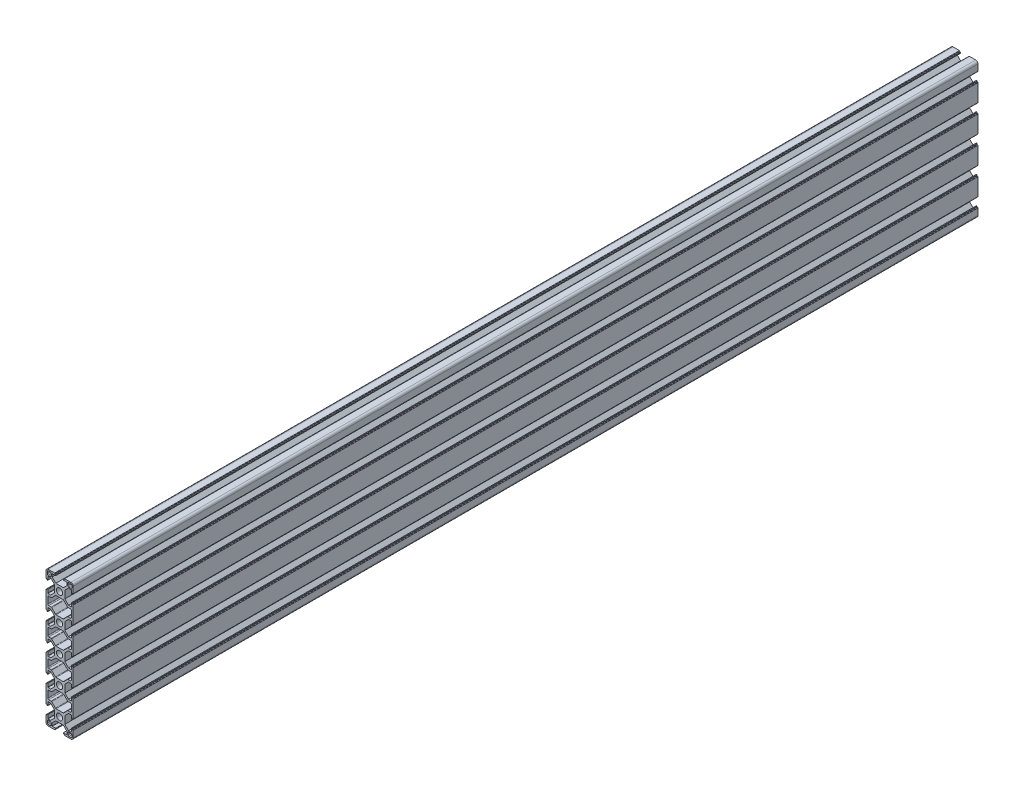
from build123d import *

# Parameters (mm, degrees)
SKETCH_1_R      = 3.4
EXTRUDE_1_DEPTH = 1000


with BuildPart() as part:
    # Эскиз1 → Бобышка-Вытянуть1 (new body)
    with BuildSketch(Plane.XY):
        with BuildLine():
            Line((-15, 8.25), (-15, 12.5))
            ThreePointArc((-15, 12.5), (-14.267766953, 14.267766953), (-12.5, 15))
            Line((-12.5, 15), (-8.25, 15))
            Line((-8.25, 15), (-5.5, 15))
            ThreePointArc((-5.5, 15), (-5.287867966, 14.912132034), (-5.2, 14.7))
            Line((-5.2, 14.7), (-5.2, 14.3))
            ThreePointArc((-5.2, 14.3), (-5.112132034, 14.087867966), (-4.9, 14))
            Line((-4.9, 14), (-4.4, 14))
            ThreePointArc((-4.4, 14), (-4.187867966, 13.912132034), (-4.1, 13.7))
            Line((-4.1, 13.7), (-4.1, 13.3))
            ThreePointArc((-4.1, 13.3), (-4.187867966, 13.087867966), (-4.4, 13))
            Line((-4.4, 13), (-7.95, 13))
            ThreePointArc((-7.95, 13), (-8.162132034, 12.912132034), (-8.25, 12.7))
            Line((-8.25, 12.7), (-8.25, 9.85))
            Line((-8.25, 9.85), (-4.2, 5.8))
            Line((-4.2, 5.8), (4.2, 5.8))
            Line((4.2, 5.8), (8.25, 9.85))
            Line((8.25, 9.85), (8.25, 12.7))
            ThreePointArc((8.25, 12.7), (8.162132034, 12.912132034), (7.95, 13))
            Line((7.95, 13), (4.4, 13))
            ThreePointArc((4.4, 13), (4.187867966, 13.087867966), (4.1, 13.3))
            Line((4.1, 13.3), (4.1, 13.7))
            ThreePointArc((4.1, 13.7), (4.187867966, 13.912132034), (4.4, 14))
            Line((4.4, 14), (4.9, 14))
            ThreePointArc((4.9, 14), (5.112132034, 14.087867966), (5.2, 14.3))
            Line((5.2, 14.3), (5.2, 14.7))
            ThreePointArc((5.2, 14.7), (5.287867966, 14.912132034), (5.5, 15))
            Line((5.5, 15), (8.25, 15))
            Line((8.25, 15), (12.5, 15))
            ThreePointArc((12.5, 15), (14.267766953, 14.267766953), (15, 12.5))
            Line((15, 12.5), (15, 8.25))
            Line((15, 8.25), (15, 5.5))
            ThreePointArc((15, 5.5), (14.912132034, 5.287867966), (14.7, 5.2))
            Line((14.7, 5.2), (14.3, 5.2))
            ThreePointArc((14.3, 5.2), (14.087867966, 5.112132034), (14, 4.9))
            Line((14, 4.9), (14, 4.4))
            ThreePointArc((14, 4.4), (13.912132034, 4.187867966), (13.7, 4.1))
            Line((13.7, 4.1), (13.3, 4.1))
            ThreePointArc((13.3, 4.1), (13.087867966, 4.187867966), (13, 4.4))
            Line((13, 4.4), (13, 7.95))
            ThreePointArc((13, 7.95), (12.912132034, 8.162132034), (12.7, 8.25))
            Line((12.7, 8.25), (9.85, 8.25))
            Line((9.85, 8.25), (5.8, 4.2))
            Line((5.8, 4.2), (5.8, -4.2))
            Line((5.8, -4.2), (9.85, -8.25))
            Line((9.85, -8.25), (12.7, -8.25))
            ThreePointArc((12.7, -8.25), (12.912132034, -8.162132034), (13, -7.95))
            Line((13, -7.95), (13, -4.4))
            ThreePointArc((13, -4.4), (13.087867966, -4.187867966), (13.3, -4.1))
            Line((13.3, -4.1), (13.7, -4.1))
            ThreePointArc((13.7, -4.1), (13.912132034, -4.187867966), (14, -4.4))
            Line((14, -4.4), (14, -4.9))
            ThreePointArc((14, -4.9), (14.087867966, -5.112132034), (14.3, -5.2))
            Line((14.3, -5.2), (14.7, -5.2))
            ThreePointArc((14.7, -5.2), (14.912132034, -5.287867966), (15, -5.5))
            Line((15, -5.5), (15, -8.25))
            Line((15, -8.25), (15, -21.75))
            Line((15, -21.75), (15, -24.5))
            ThreePointArc((15, -24.5), (14.912132034, -24.712132034), (14.7, -24.8))
            Line((14.7, -24.8), (14.3, -24.8))
            ThreePointArc((14.3, -24.8), (14.087867966, -24.887867966), (14, -25.1))
            Line((14, -25.1), (14, -25.6))
            ThreePointArc((14, -25.6), (13.912132034, -25.812132034), (13.7, -25.9))
            Line((13.7, -25.9), (13.3, -25.9))
            ThreePointArc((13.3, -25.9), (13.087867966, -25.812132034), (13, -25.6))
            Line((13, -25.6), (13, -22.05))
            ThreePointArc((13, -22.05), (12.912132034, -21.837867966), (12.7, -21.75))
            Line((12.7, -21.75), (9.85, -21.75))
            Line((9.85, -21.75), (5.8, -25.8))
            Line((5.8, -25.8), (5.8, -34.2))
            Line((5.8, -34.2), (9.85, -38.25))
            Line((9.85, -38.25), (12.7, -38.25))
            ThreePointArc((12.7, -38.25), (12.912132034, -38.162132034), (13, -37.95))
            Line((13, -37.95), (13, -34.4))
            ThreePointArc((13, -34.4), (13.087867966, -34.187867966), (13.3, -34.1))
            Line((13.3, -34.1), (13.7, -34.1))
            ThreePointArc((13.7, -34.1), (13.912132034, -34.187867966), (14, -34.4))
            Line((14, -34.4), (14, -34.9))
            ThreePointArc((14, -34.9), (14.087867966, -35.112132034), (14.3, -35.2))
            Line((14.3, -35.2), (14.7, -35.2))
            ThreePointArc((14.7, -35.2), (14.912132034, -35.287867966), (15, -35.5))
            Line((15, -35.5), (15, -38.25))
            Line((15, -38.25), (15, -51.75))
            Line((15, -51.75), (15, -54.5))
            ThreePointArc((15, -54.5), (14.912132034, -54.712132034), (14.7, -54.8))
            Line((14.7, -54.8), (14.3, -54.8))
            ThreePointArc((14.3, -54.8), (14.087867966, -54.887867966), (14, -55.1))
            Line((14, -55.1), (14, -55.6))
            ThreePointArc((14, -55.6), (13.912132034, -55.812132034), (13.7, -55.9))
            Line((13.7, -55.9), (13.3, -55.9))
            ThreePointArc((13.3, -55.9), (13.087867966, -55.812132034), (13, -55.6))
            Line((13, -55.6), (13, -52.05))
            ThreePointArc((13, -52.05), (12.912132034, -51.837867966), (12.7, -51.75))
            Line((12.7, -51.75), (9.85, -51.75))
            Line((9.85, -51.75), (5.8, -55.8))
            Line((5.8, -55.8), (5.8, -64.2))
            Line((5.8, -64.2), (9.85, -68.25))
            Line((9.85, -68.25), (12.7, -68.25))
            ThreePointArc((12.7, -68.25), (12.912132034, -68.162132034), (13, -67.95))
            Line((13, -67.95), (13, -64.4))
            ThreePointArc((13, -64.4), (13.087867966, -64.187867966), (13.3, -64.1))
            Line((13.3, -64.1), (13.7, -64.1))
            ThreePointArc((13.7, -64.1), (13.912132034, -64.187867966), (14, -64.4))
            Line((14, -64.4), (14, -64.9))
            ThreePointArc((14, -64.9), (14.087867966, -65.112132034), (14.3, -65.2))
            Line((14.3, -65.2), (14.7, -65.2))
            ThreePointArc((14.7, -65.2), (14.912132034, -65.287867966), (15, -65.5))
            Line((15, -65.5), (15, -68.25))
            Line((15, -68.25), (15, -81.75))
            Line((15, -81.75), (15, -84.5))
            ThreePointArc((15, -84.5), (14.912132034, -84.712132034), (14.7, -84.8))
            Line((14.7, -84.8), (14.3, -84.8))
            ThreePointArc((14.3, -84.8), (14.087867966, -84.887867966), (14, -85.1))
            Line((14, -85.1), (14, -85.6))
            ThreePointArc((14, -85.6), (13.912132034, -85.812132034), (13.7, -85.9))
            Line((13.7, -85.9), (13.3, -85.9))
            ThreePointArc((13.3, -85.9), (13.087867966, -85.812132034), (13, -85.6))
            Line((13, -85.6), (13, -82.05))
            ThreePointArc((13, -82.05), (12.912132034, -81.837867966), (12.7, -81.75))
            Line((12.7, -81.75), (9.85, -81.75))
            Line((9.85, -81.75), (5.8, -85.8))
            Line((5.8, -85.8), (5.8, -94.2))
            Line((5.8, -94.2), (9.85, -98.25))
            Line((9.85, -98.25), (12.7, -98.25))
            ThreePointArc((12.7, -98.25), (12.912132034, -98.162132034), (13, -97.95))
            Line((13, -97.95), (13, -94.4))
            ThreePointArc((13, -94.4), (13.087867966, -94.187867966), (13.3, -94.1))
            Line((13.3, -94.1), (13.7, -94.1))
            ThreePointArc((13.7, -94.1), (13.912132034, -94.187867966), (14, -94.4))
            Line((14, -94.4), (14, -94.9))
            ThreePointArc((14, -94.9), (14.087867966, -95.112132034), (14.3, -95.2))
            Line((14.3, -95.2), (14.7, -95.2))
            ThreePointArc((14.7, -95.2), (14.912132034, -95.287867966), (15, -95.5))
            Line((15, -95.5), (15, -98.25))
            Line((15, -98.25), (15, -111.75))
            Line((15, -111.75), (15, -114.5))
            ThreePointArc((15, -114.5), (14.912132034, -114.712132034), (14.7, -114.8))
            Line((14.7, -114.8), (14.3, -114.8))
            ThreePointArc((14.3, -114.8), (14.087867966, -114.887867966), (14, -115.1))
            Line((14, -115.1), (14, -115.6))
            ThreePointArc((14, -115.6), (13.912132034, -115.812132034), (13.7, -115.9))
            Line((13.7, -115.9), (13.3, -115.9))
            ThreePointArc((13.3, -115.9), (13.087867966, -115.812132034), (13, -115.6))
            Line((13, -115.6), (13, -112.05))
            ThreePointArc((13, -112.05), (12.912132034, -111.837867966), (12.7, -111.75))
            Line((12.7, -111.75), (9.85, -111.75))
            Line((9.85, -111.75), (5.8, -115.8))
            Line((5.8, -115.8), (5.8, -124.2))
            Line((5.8, -124.2), (9.85, -128.25))
            Line((9.85, -128.25), (12.7, -128.25))
            ThreePointArc((12.7, -128.25), (12.912132034, -128.162132034), (13, -127.95))
            Line((13, -127.95), (13, -124.4))
            ThreePointArc((13, -124.4), (13.087867966, -124.187867966), (13.3, -124.1))
            Line((13.3, -124.1), (13.7, -124.1))
            ThreePointArc((13.7, -124.1), (13.912132034, -124.187867966), (14, -124.4))
            Line((14, -124.4), (14, -124.9))
            ThreePointArc((14, -124.9), (14.087867966, -125.112132034), (14.3, -125.2))
            Line((14.3, -125.2), (14.7, -125.2))
            ThreePointArc((14.7, -125.2), (14.912132034, -125.287867966), (15, -125.5))
            Line((15, -125.5), (15, -128.25))
            Line((15, -128.25), (15, -132.5))
            ThreePointArc((15, -132.5), (14.267766953, -134.267766953), (12.5, -135))
            Line((12.5, -135), (8.25, -135))
            Line((8.25, -135), (5.5, -135))
            ThreePointArc((5.5, -135), (5.287867966, -134.912132034), (5.2, -134.7))
            Line((5.2, -134.7), (5.2, -134.3))
            ThreePointArc((5.2, -134.3), (5.112132034, -134.087867966), (4.9, -134))
            Line((4.9, -134), (4.4, -134))
            ThreePointArc((4.4, -134), (4.187867966, -133.912132034), (4.1, -133.7))
            Line((4.1, -133.7), (4.1, -133.3))
            ThreePointArc((4.1, -133.3), (4.187867966, -133.087867966), (4.4, -133))
            Line((4.4, -133), (7.95, -133))
            ThreePointArc((7.95, -133), (8.162132034, -132.912132034), (8.25, -132.7))
            Line((8.25, -132.7), (8.25, -129.85))
            Line((8.25, -129.85), (4.2, -125.8))
            Line((4.2, -125.8), (-4.2, -125.8))
            Line((-4.2, -125.8), (-8.25, -129.85))
            Line((-8.25, -129.85), (-8.25, -132.7))
            ThreePointArc((-8.25, -132.7), (-8.162132034, -132.912132034), (-7.95, -133))
            Line((-7.95, -133), (-4.4, -133))
            ThreePointArc((-4.4, -133), (-4.187867966, -133.087867966), (-4.1, -133.3))
            Line((-4.1, -133.3), (-4.1, -133.7))
            ThreePointArc((-4.1, -133.7), (-4.187867966, -133.912132034), (-4.4, -134))
            Line((-4.4, -134), (-4.9, -134))
            ThreePointArc((-4.9, -134), (-5.112132034, -134.087867966), (-5.2, -134.3))
            Line((-5.2, -134.3), (-5.2, -134.7))
            ThreePointArc((-5.2, -134.7), (-5.287867966, -134.912132034), (-5.5, -135))
            Line((-5.5, -135), (-8.25, -135))
            Line((-8.25, -135), (-12.5, -135))
            ThreePointArc((-12.5, -135), (-14.267766953, -134.267766953), (-15, -132.5))
            Line((-15, -132.5), (-15, -128.25))
            Line((-15, -128.25), (-15, -125.5))
            ThreePointArc((-15, -125.5), (-14.912132034, -125.287867966), (-14.7, -125.2))
            Line((-14.7, -125.2), (-14.3, -125.2))
            ThreePointArc((-14.3, -125.2), (-14.087867966, -125.112132034), (-14, -124.9))
            Line((-14, -124.9), (-14, -124.4))
            ThreePointArc((-14, -124.4), (-13.912132034, -124.187867966), (-13.7, -124.1))
            Line((-13.7, -124.1), (-13.3, -124.1))
            ThreePointArc((-13.3, -124.1), (-13.087867966, -124.187867966), (-13, -124.4))
            Line((-13, -124.4), (-13, -127.95))
            ThreePointArc((-13, -127.95), (-12.912132034, -128.162132034), (-12.7, -128.25))
            Line((-12.7, -128.25), (-9.85, -128.25))
            Line((-9.85, -128.25), (-5.8, -124.2))
            Line((-5.8, -124.2), (-5.8, -115.8))
            Line((-5.8, -115.8), (-9.85, -111.75))
            Line((-9.85, -111.75), (-12.7, -111.75))
            ThreePointArc((-12.7, -111.75), (-12.912132034, -111.837867966), (-13, -112.05))
            Line((-13, -112.05), (-13, -115.6))
            ThreePointArc((-13, -115.6), (-13.087867966, -115.812132034), (-13.3, -115.9))
            Line((-13.3, -115.9), (-13.7, -115.9))
            ThreePointArc((-13.7, -115.9), (-13.912132034, -115.812132034), (-14, -115.6))
            Line((-14, -115.6), (-14, -115.1))
            ThreePointArc((-14, -115.1), (-14.087867966, -114.887867966), (-14.3, -114.8))
            Line((-14.3, -114.8), (-14.7, -114.8))
            ThreePointArc((-14.7, -114.8), (-14.912132034, -114.712132034), (-15, -114.5))
            Line((-15, -114.5), (-15, -111.75))
            Line((-15, -111.75), (-15, -98.25))
            Line((-15, -98.25), (-15, -95.5))
            ThreePointArc((-15, -95.5), (-14.912132034, -95.287867966), (-14.7, -95.2))
            Line((-14.7, -95.2), (-14.3, -95.2))
            ThreePointArc((-14.3, -95.2), (-14.087867966, -95.112132034), (-14, -94.9))
            Line((-14, -94.9), (-14, -94.4))
            ThreePointArc((-14, -94.4), (-13.912132034, -94.187867966), (-13.7, -94.1))
            Line((-13.7, -94.1), (-13.3, -94.1))
            ThreePointArc((-13.3, -94.1), (-13.087867966, -94.187867966), (-13, -94.4))
            Line((-13, -94.4), (-13, -97.95))
            ThreePointArc((-13, -97.95), (-12.912132034, -98.162132034), (-12.7, -98.25))
            Line((-12.7, -98.25), (-9.85, -98.25))
            Line((-9.85, -98.25), (-5.8, -94.2))
            Line((-5.8, -94.2), (-5.8, -85.8))
            Line((-5.8, -85.8), (-9.85, -81.75))
            Line((-9.85, -81.75), (-12.7, -81.75))
            ThreePointArc((-12.7, -81.75), (-12.912132034, -81.837867966), (-13, -82.05))
            Line((-13, -82.05), (-13, -85.6))
            ThreePointArc((-13, -85.6), (-13.087867966, -85.812132034), (-13.3, -85.9))
            Line((-13.3, -85.9), (-13.7, -85.9))
            ThreePointArc((-13.7, -85.9), (-13.912132034, -85.812132034), (-14, -85.6))
            Line((-14, -85.6), (-14, -85.1))
            ThreePointArc((-14, -85.1), (-14.087867966, -84.887867966), (-14.3, -84.8))
            Line((-14.3, -84.8), (-14.7, -84.8))
            ThreePointArc((-14.7, -84.8), (-14.912132034, -84.712132034), (-15, -84.5))
            Line((-15, -84.5), (-15, -81.75))
            Line((-15, -81.75), (-15, -68.25))
            Line((-15, -68.25), (-15, -65.5))
            ThreePointArc((-15, -65.5), (-14.912132034, -65.287867966), (-14.7, -65.2))
            Line((-14.7, -65.2), (-14.3, -65.2))
            ThreePointArc((-14.3, -65.2), (-14.087867966, -65.112132034), (-14, -64.9))
            Line((-14, -64.9), (-14, -64.4))
            ThreePointArc((-14, -64.4), (-13.912132034, -64.187867966), (-13.7, -64.1))
            Line((-13.7, -64.1), (-13.3, -64.1))
            ThreePointArc((-13.3, -64.1), (-13.087867966, -64.187867966), (-13, -64.4))
            Line((-13, -64.4), (-13, -67.95))
            ThreePointArc((-13, -67.95), (-12.912132034, -68.162132034), (-12.7, -68.25))
            Line((-12.7, -68.25), (-9.85, -68.25))
            Line((-9.85, -68.25), (-5.8, -64.2))
            Line((-5.8, -64.2), (-5.8, -55.8))
            Line((-5.8, -55.8), (-9.85, -51.75))
            Line((-9.85, -51.75), (-12.7, -51.75))
            ThreePointArc((-12.7, -51.75), (-12.912132034, -51.837867966), (-13, -52.05))
            Line((-13, -52.05), (-13, -55.6))
            ThreePointArc((-13, -55.6), (-13.087867966, -55.812132034), (-13.3, -55.9))
            Line((-13.3, -55.9), (-13.7, -55.9))
            ThreePointArc((-13.7, -55.9), (-13.912132034, -55.812132034), (-14, -55.6))
            Line((-14, -55.6), (-14, -55.1))
            ThreePointArc((-14, -55.1), (-14.087867966, -54.887867966), (-14.3, -54.8))
            Line((-14.3, -54.8), (-14.7, -54.8))
            ThreePointArc((-14.7, -54.8), (-14.912132034, -54.712132034), (-15, -54.5))
            Line((-15, -54.5), (-15, -51.75))
            Line((-15, -51.75), (-15, -38.25))
            Line((-15, -38.25), (-15, -35.5))
            ThreePointArc((-15, -35.5), (-14.912132034, -35.287867966), (-14.7, -35.2))
            Line((-14.7, -35.2), (-14.3, -35.2))
            ThreePointArc((-14.3, -35.2), (-14.087867966, -35.112132034), (-14, -34.9))
            Line((-14, -34.9), (-14, -34.4))
            ThreePointArc((-14, -34.4), (-13.912132034, -34.187867966), (-13.7, -34.1))
            Line((-13.7, -34.1), (-13.3, -34.1))
            ThreePointArc((-13.3, -34.1), (-13.087867966, -34.187867966), (-13, -34.4))
            Line((-13, -34.4), (-13, -37.95))
            ThreePointArc((-13, -37.95), (-12.912132034, -38.162132034), (-12.7, -38.25))
            Line((-12.7, -38.25), (-9.85, -38.25))
            Line((-9.85, -38.25), (-5.8, -34.2))
            Line((-5.8, -34.2), (-5.8, -25.8))
            Line((-5.8, -25.8), (-9.85, -21.75))
            Line((-9.85, -21.75), (-12.7, -21.75))
            ThreePointArc((-12.7, -21.75), (-12.912132034, -21.837867966), (-13, -22.05))
            Line((-13, -22.05), (-13, -25.6))
            ThreePointArc((-13, -25.6), (-13.087867966, -25.812132034), (-13.3, -25.9))
            Line((-13.3, -25.9), (-13.7, -25.9))
            ThreePointArc((-13.7, -25.9), (-13.912132034, -25.812132034), (-14, -25.6))
            Line((-14, -25.6), (-14, -25.1))
            ThreePointArc((-14, -25.1), (-14.087867966, -24.887867966), (-14.3, -24.8))
            Line((-14.3, -24.8), (-14.7, -24.8))
            ThreePointArc((-14.7, -24.8), (-14.912132034, -24.712132034), (-15, -24.5))
            Line((-15, -24.5), (-15, -21.75))
            Line((-15, -21.75), (-15, -8.25))
            Line((-15, -8.25), (-15, -5.5))
            ThreePointArc((-15, -5.5), (-14.912132034, -5.287867966), (-14.7, -5.2))
            Line((-14.7, -5.2), (-14.3, -5.2))
            ThreePointArc((-14.3, -5.2), (-14.087867966, -5.112132034), (-14, -4.9))
            Line((-14, -4.9), (-14, -4.4))
            ThreePointArc((-14, -4.4), (-13.912132034, -4.187867966), (-13.7, -4.1))
            Line((-13.7, -4.1), (-13.3, -4.1))
            ThreePointArc((-13.3, -4.1), (-13.087867966, -4.187867966), (-13, -4.4))
            Line((-13, -4.4), (-13, -7.95))
            ThreePointArc((-13, -7.95), (-12.912132034, -8.162132034), (-12.7, -8.25))
            Line((-12.7, -8.25), (-9.85, -8.25))
            Line((-9.85, -8.25), (-5.8, -4.2))
            Line((-5.8, -4.2), (-5.8, 4.2))
            Line((-5.8, 4.2), (-9.85, 8.25))
            Line((-9.85, 8.25), (-12.7, 8.25))
            ThreePointArc((-12.7, 8.25), (-12.912132034, 8.162132034), (-13, 7.95))
            Line((-13, 7.95), (-13, 4.4))
            ThreePointArc((-13, 4.4), (-13.087867966, 4.187867966), (-13.3, 4.1))
            Line((-13.3, 4.1), (-13.7, 4.1))
            ThreePointArc((-13.7, 4.1), (-13.912132034, 4.187867966), (-14, 4.4))
            Line((-14, 4.4), (-14, 4.9))
            ThreePointArc((-14, 4.9), (-14.087867966, 5.112132034), (-14.3, 5.2))
            Line((-14.3, 5.2), (-14.7, 5.2))
            ThreePointArc((-14.7, 5.2), (-14.912132034, 5.287867966), (-15, 5.5))
            Line((-15, 5.5), (-15, 8.25))
        make_face()
        Circle(SKETCH_1_R, mode=Mode.SUBTRACT)
        with Locations((0, -30)):
            Circle(SKETCH_1_R, mode=Mode.SUBTRACT)
        with Locations((0, -60)):
            Circle(SKETCH_1_R, mode=Mode.SUBTRACT)
        with Locations((0, -90)):
            Circle(SKETCH_1_R, mode=Mode.SUBTRACT)
        with Locations((0, -120)):
            Circle(SKETCH_1_R, mode=Mode.SUBTRACT)
        with BuildLine():
            Line((12.55, 9.35), (10.35, 9.35))
            ThreePointArc((10.35, 9.35), (9.642893219, 9.642893219), (9.35, 10.35))
            Line((9.35, 10.35), (9.35, 12.55))
            ThreePointArc((9.35, 12.55), (9.642893219, 13.257106781), (10.35, 13.55))
            Line((10.35, 13.55), (12.55, 13.55))
            ThreePointArc((12.55, 13.55), (13.257106781, 13.257106781), (13.55, 12.55))
            Line((13.55, 12.55), (13.55, 10.35))
            ThreePointArc((13.55, 10.35), (13.257106781, 9.642893219), (12.55, 9.35))
        make_face(mode=Mode.SUBTRACT)
        with BuildLine():
            Line((-12.55, 13.55), (-10.35, 13.55))
            ThreePointArc((-10.35, 13.55), (-9.642893219, 13.257106781), (-9.35, 12.55))
            Line((-9.35, 12.55), (-9.35, 10.35))
            ThreePointArc((-9.35, 10.35), (-9.642893219, 9.642893219), (-10.35, 9.35))
            Line((-10.35, 9.35), (-12.55, 9.35))
            ThreePointArc((-12.55, 9.35), (-13.257106781, 9.642893219), (-13.55, 10.35))
            Line((-13.55, 10.35), (-13.55, 12.55))
            ThreePointArc((-13.55, 12.55), (-13.257106781, 13.257106781), (-12.55, 13.55))
        make_face(mode=Mode.SUBTRACT)
        with BuildLine():
            Line((8.695836944, -40.207106781), (4.581623382, -36.092893219))
            ThreePointArc((4.581623382, -36.092893219), (4.257200033, -35.876120467), (3.8745166, -35.8))
            Line((3.8745166, -35.8), (-3.8745166, -35.8))
            ThreePointArc((-3.8745166, -35.8), (-4.257200033, -35.876120467), (-4.581623382, -36.092893219))
            Line((-4.581623382, -36.092893219), (-8.695836944, -40.207106781))
            ThreePointArc((-8.695836944, -40.207106781), (-9.020260293, -40.423879533), (-9.402943725, -40.5))
            Line((-9.402943725, -40.5), (-12, -40.5))
            ThreePointArc((-12, -40.5), (-12.707106781, -40.792893219), (-13, -41.5))
            Line((-13, -41.5), (-13, -48.5))
            ThreePointArc((-13, -48.5), (-12.707106781, -49.207106781), (-12, -49.5))
            Line((-12, -49.5), (-9.402943725, -49.5))
            ThreePointArc((-9.402943725, -49.5), (-9.020260293, -49.576120467), (-8.695836944, -49.792893219))
            Line((-8.695836944, -49.792893219), (-4.581623382, -53.907106781))
            ThreePointArc((-4.581623382, -53.907106781), (-4.257200033, -54.123879533), (-3.8745166, -54.2))
            Line((-3.8745166, -54.2), (3.8745166, -54.2))
            ThreePointArc((3.8745166, -54.2), (4.257200033, -54.123879533), (4.581623382, -53.907106781))
            Line((4.581623382, -53.907106781), (8.695836944, -49.792893219))
            ThreePointArc((8.695836944, -49.792893219), (9.020260293, -49.576120467), (9.402943725, -49.5))
            Line((9.402943725, -49.5), (12, -49.5))
            ThreePointArc((12, -49.5), (12.707106781, -49.207106781), (13, -48.5))
            Line((13, -48.5), (13, -41.5))
            ThreePointArc((13, -41.5), (12.707106781, -40.792893219), (12, -40.5))
            Line((12, -40.5), (9.402943725, -40.5))
            ThreePointArc((9.402943725, -40.5), (9.020260293, -40.423879533), (8.695836944, -40.207106781))
        make_face(mode=Mode.SUBTRACT)
        with BuildLine():
            Line((-13, -18.5), (-13, -11.5))
            ThreePointArc((-13, -11.5), (-12.707106781, -10.792893219), (-12, -10.5))
            Line((-12, -10.5), (-9.402943725, -10.5))
            ThreePointArc((-9.402943725, -10.5), (-9.020260293, -10.423879533), (-8.695836944, -10.207106781))
            Line((-8.695836944, -10.207106781), (-4.581623382, -6.092893219))
            ThreePointArc((-4.581623382, -6.092893219), (-4.257200033, -5.876120467), (-3.8745166, -5.8))
            Line((-3.8745166, -5.8), (3.8745166, -5.8))
            ThreePointArc((3.8745166, -5.8), (4.257200033, -5.876120467), (4.581623382, -6.092893219))
            Line((4.581623382, -6.092893219), (8.695836944, -10.207106781))
            ThreePointArc((8.695836944, -10.207106781), (9.020260293, -10.423879533), (9.402943725, -10.5))
            Line((9.402943725, -10.5), (12, -10.5))
            ThreePointArc((12, -10.5), (12.707106781, -10.792893219), (13, -11.5))
            Line((13, -11.5), (13, -18.5))
            ThreePointArc((13, -18.5), (12.707106781, -19.207106781), (12, -19.5))
            Line((12, -19.5), (9.402943725, -19.5))
            ThreePointArc((9.402943725, -19.5), (9.020260293, -19.576120467), (8.695836944, -19.792893219))
            Line((8.695836944, -19.792893219), (4.581623382, -23.907106781))
            ThreePointArc((4.581623382, -23.907106781), (4.257200033, -24.123879533), (3.8745166, -24.2))
            Line((3.8745166, -24.2), (-3.8745166, -24.2))
            ThreePointArc((-3.8745166, -24.2), (-4.257200033, -24.123879533), (-4.581623382, -23.907106781))
            Line((-4.581623382, -23.907106781), (-8.695836944, -19.792893219))
            ThreePointArc((-8.695836944, -19.792893219), (-9.020260293, -19.576120467), (-9.402943725, -19.5))
            Line((-9.402943725, -19.5), (-12, -19.5))
            ThreePointArc((-12, -19.5), (-12.707106781, -19.207106781), (-13, -18.5))
        make_face(mode=Mode.SUBTRACT)
        with BuildLine():
            Line((8.695836944, -70.207106781), (4.581623382, -66.092893219))
            ThreePointArc((4.581623382, -66.092893219), (4.257200033, -65.876120467), (3.8745166, -65.8))
            Line((3.8745166, -65.8), (-3.8745166, -65.8))
            ThreePointArc((-3.8745166, -65.8), (-4.257200033, -65.876120467), (-4.581623382, -66.092893219))
            Line((-4.581623382, -66.092893219), (-8.695836944, -70.207106781))
            ThreePointArc((-8.695836944, -70.207106781), (-9.020260293, -70.423879533), (-9.402943725, -70.5))
            Line((-9.402943725, -70.5), (-12, -70.5))
            ThreePointArc((-12, -70.5), (-12.707106781, -70.792893219), (-13, -71.5))
            Line((-13, -71.5), (-13, -78.5))
            ThreePointArc((-13, -78.5), (-12.707106781, -79.207106781), (-12, -79.5))
            Line((-12, -79.5), (-9.402943725, -79.5))
            ThreePointArc((-9.402943725, -79.5), (-9.020260293, -79.576120467), (-8.695836944, -79.792893219))
            Line((-8.695836944, -79.792893219), (-4.581623382, -83.907106781))
            ThreePointArc((-4.581623382, -83.907106781), (-4.257200033, -84.123879533), (-3.8745166, -84.2))
            Line((-3.8745166, -84.2), (3.8745166, -84.2))
            ThreePointArc((3.8745166, -84.2), (4.257200033, -84.123879533), (4.581623382, -83.907106781))
            Line((4.581623382, -83.907106781), (8.695836944, -79.792893219))
            ThreePointArc((8.695836944, -79.792893219), (9.020260293, -79.576120467), (9.402943725, -79.5))
            Line((9.402943725, -79.5), (12, -79.5))
            ThreePointArc((12, -79.5), (12.707106781, -79.207106781), (13, -78.5))
            Line((13, -78.5), (13, -71.5))
            ThreePointArc((13, -71.5), (12.707106781, -70.792893219), (12, -70.5))
            Line((12, -70.5), (9.402943725, -70.5))
            ThreePointArc((9.402943725, -70.5), (9.020260293, -70.423879533), (8.695836944, -70.207106781))
        make_face(mode=Mode.SUBTRACT)
        with BuildLine():
            Line((8.695836944, -100.207106781), (4.581623382, -96.092893219))
            ThreePointArc((4.581623382, -96.092893219), (4.257200033, -95.876120467), (3.8745166, -95.8))
            Line((3.8745166, -95.8), (-3.8745166, -95.8))
            ThreePointArc((-3.8745166, -95.8), (-4.257200033, -95.876120467), (-4.581623382, -96.092893219))
            Line((-4.581623382, -96.092893219), (-8.695836944, -100.207106781))
            ThreePointArc((-8.695836944, -100.207106781), (-9.020260293, -100.423879533), (-9.402943725, -100.5))
            Line((-9.402943725, -100.5), (-12, -100.5))
            ThreePointArc((-12, -100.5), (-12.707106781, -100.792893219), (-13, -101.5))
            Line((-13, -101.5), (-13, -108.5))
            ThreePointArc((-13, -108.5), (-12.707106781, -109.207106781), (-12, -109.5))
            Line((-12, -109.5), (-9.402943725, -109.5))
            ThreePointArc((-9.402943725, -109.5), (-9.020260293, -109.576120467), (-8.695836944, -109.792893219))
            Line((-8.695836944, -109.792893219), (-4.581623382, -113.907106781))
            ThreePointArc((-4.581623382, -113.907106781), (-4.257200033, -114.123879533), (-3.8745166, -114.2))
            Line((-3.8745166, -114.2), (3.8745166, -114.2))
            ThreePointArc((3.8745166, -114.2), (4.257200033, -114.123879533), (4.581623382, -113.907106781))
            Line((4.581623382, -113.907106781), (8.695836944, -109.792893219))
            ThreePointArc((8.695836944, -109.792893219), (9.020260293, -109.576120467), (9.402943725, -109.5))
            Line((9.402943725, -109.5), (12, -109.5))
            ThreePointArc((12, -109.5), (12.707106781, -109.207106781), (13, -108.5))
            Line((13, -108.5), (13, -101.5))
            ThreePointArc((13, -101.5), (12.707106781, -100.792893219), (12, -100.5))
            Line((12, -100.5), (9.402943725, -100.5))
            ThreePointArc((9.402943725, -100.5), (9.020260293, -100.423879533), (8.695836944, -100.207106781))
        make_face(mode=Mode.SUBTRACT)
        with BuildLine():
            Line((13.55, -132.55), (13.55, -130.35))
            ThreePointArc((13.55, -130.35), (13.257106781, -129.642893219), (12.55, -129.35))
            Line((12.55, -129.35), (10.35, -129.35))
            ThreePointArc((10.35, -129.35), (9.642893219, -129.642893219), (9.35, -130.35))
            Line((9.35, -130.35), (9.35, -132.55))
            ThreePointArc((9.35, -132.55), (9.642893219, -133.257106781), (10.35, -133.55))
            Line((10.35, -133.55), (12.55, -133.55))
            ThreePointArc((12.55, -133.55), (13.257106781, -133.257106781), (13.55, -132.55))
        make_face(mode=Mode.SUBTRACT)
        with BuildLine():
            Line((-12.55, -133.55), (-10.35, -133.55))
            ThreePointArc((-10.35, -133.55), (-9.642893219, -133.257106781), (-9.35, -132.55))
            Line((-9.35, -132.55), (-9.35, -130.35))
            ThreePointArc((-9.35, -130.35), (-9.642893219, -129.642893219), (-10.35, -129.35))
            Line((-10.35, -129.35), (-12.55, -129.35))
            ThreePointArc((-12.55, -129.35), (-13.257106781, -129.642893219), (-13.55, -130.35))
            Line((-13.55, -130.35), (-13.55, -132.55))
            ThreePointArc((-13.55, -132.55), (-13.257106781, -133.257106781), (-12.55, -133.55))
        make_face(mode=Mode.SUBTRACT)
    extrude(amount=EXTRUDE_1_DEPTH)


solid = part.part
